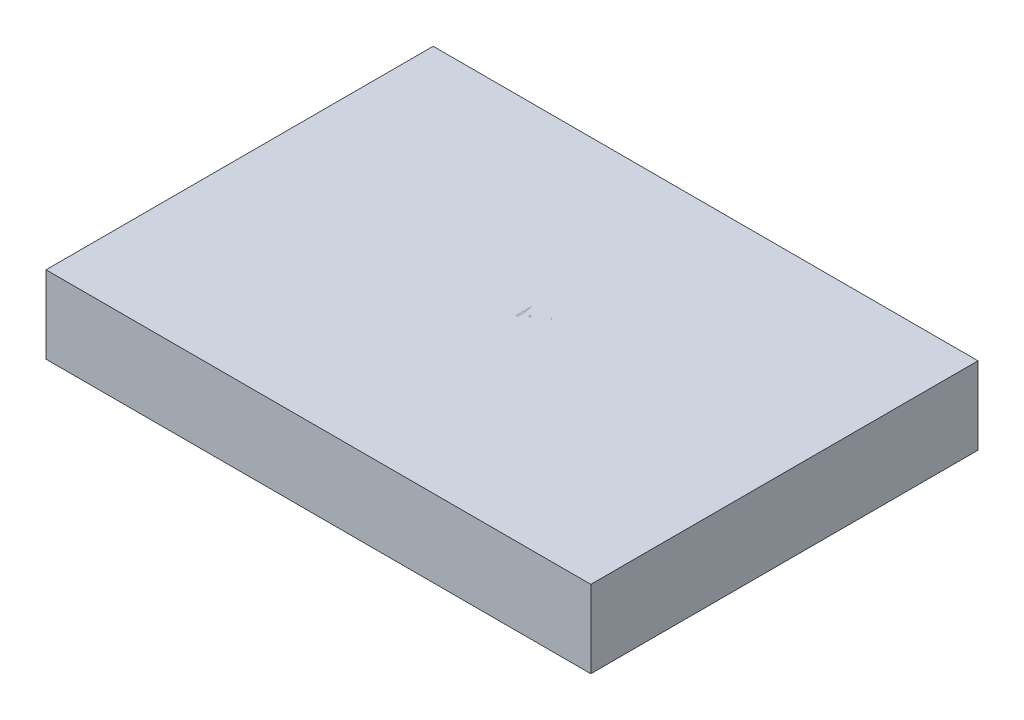
from build123d import *

# Parameters (mm, degrees)
SKETCH1_W             = 100.076
SKETCH1_H             = 71.12
BOSS_EXTRUDE1_DEPTH   = 14.224
BOSS_EXTRUDE2_DEPTH   = 0.1
BOSS_EXTRUDE2_2_DEPTH = 0.1
BOSS_EXTRUDE2_3_DEPTH = 0.1
BOSS_EXTRUDE2_4_DEPTH = 0.1
BOSS_EXTRUDE2_5_DEPTH = 0.1
BOSS_EXTRUDE2_6_DEPTH = 0.1
BOSS_EXTRUDE2_7_DEPTH = 0.1


with BuildPart() as part:
    # Sketch1 → Boss-Extrude1 (new body)
    with BuildSketch(Plane(origin=(0, 0, 0), x_dir=(1, 0, 0), z_dir=(0, 1, 0))):
        Rectangle(SKETCH1_W, SKETCH1_H)
    extrude(amount=BOSS_EXTRUDE1_DEPTH)


with BuildPart() as body_2:
    # Sketch3 → Boss-Extrude2 (new body)
    with BuildSketch(Plane(origin=(0, 14.224, 0), x_dir=(1, 0, 0), z_dir=(0, 1, 0))):
        with BuildLine():
            Line((0.407051282, 3.175), (1.026532452, 3.175))
            add(Edge.make_bspline(
                [(1.026532452, 3.175), (1.056856857, 3.174840569), (1.115633102, 3.174531553), (1.201103595, 3.169738998), (1.281157873, 3.163204241), (1.355819153, 3.152835514), (1.425052933, 3.140324401), (1.489067861, 3.125173468), (1.547660374, 3.107006469), (1.617612642, 3.078117342), (1.697369242, 3.035188468), (1.783727784, 2.97175327), (1.857573058, 2.894163107), (1.921242074, 2.806639555), (1.971861661, 2.710359248), (2.008482381, 2.607616984), (2.031667025, 2.499737975), (2.03405139, 2.425675949), (2.03525641, 2.388246194)],
                knots=[0, 0, 0, 0, 9.0959e-05, 0.000176302, 0.000256745, 0.000331852, 0.000402335, 0.000467743, 0.000529095, 0.000586142, 0.000694565, 0.000800018, 0.00090617, 0.001014562, 0.001123809, 0.001231237, 0.001341005, 0.001453163, 0.001453163, 0.001453163, 0.001453163], degree=3))
            add(Edge.make_bspline(
                [(2.03525641, 2.388246194), (2.034264705, 2.353182804), (2.032315911, 2.284279937), (2.013680693, 2.183501709), (1.984506372, 2.087570246), (1.943952325, 1.996835654), (1.891245514, 1.913348019), (1.828781182, 1.836433856), (1.753418654, 1.769349683), (1.696955144, 1.731845764), (1.668274239, 1.712795473)],
                knots=[0, 0, 0, 0, 0.000105099, 0.000206529, 0.000306317, 0.000405381, 0.000503676, 0.000601724, 0.00070171, 0.000804929, 0.000804929, 0.000804929, 0.000804929], degree=3))
            add(Edge.make_bspline(
                [(1.668274239, 1.712795473), (1.704342627, 1.698947938), (1.773350388, 1.672454174), (1.868315556, 1.625613431), (1.950135165, 1.574666374), (2.019438291, 1.519029624), (2.078708878, 1.459059489), (2.130464046, 1.393876635), (2.174625007, 1.322630762), (2.212464588, 1.246064698), (2.241990959, 1.164960259), (2.264103387, 1.080078197), (2.276773858, 0.991722887), (2.278576933, 0.931592578), (2.279487179, 0.901236979)],
                knots=[0, 0, 0, 0, 0.000115862, 0.000221672, 0.000317136, 0.000404447, 0.000487649, 0.000569596, 0.000653599, 0.000738647, 0.000825372, 0.000912066, 0.001001383, 0.001092443, 0.001092443, 0.001092443, 0.001092443], degree=3))
            add(Edge.make_bspline(
                [(2.279487179, 0.901236979), (2.278601041, 0.870242745), (2.276857537, 0.809260721), (2.263994277, 0.719675707), (2.242214587, 0.634064148), (2.212214333, 0.551872304), (2.173059948, 0.473259182), (2.12540958, 0.398135721), (2.068593805, 0.327256721), (2.005036774, 0.259834577), (1.933134684, 0.199212227), (1.855559678, 0.145222979), (1.771334802, 0.100821908), (1.681843351, 0.063523803), (1.586081435, 0.035032987), (1.48447907, 0.015100724), (1.377123882, 0.00167044), (1.303455036, 0.000566261), (1.26567508, 0)],
                knots=[0, 0, 0, 0, 9.2965e-05, 0.000182912, 0.000270839, 0.000357564, 0.000444886, 0.000533812, 0.000623905, 0.000717027, 0.000811331, 0.000905539, 0.001000006, 0.001096388, 0.001195991, 0.001299146, 0.001406751, 0.001520027, 0.001520027, 0.001520027, 0.001520027], degree=3))
            Line((1.26567508, 0), (0.407051282, 0))
            Line((0.407051282, 0), (0.407051282, 3.175))
        make_face()
        with BuildLine():
            Line((0.691987179, 2.849358974), (0.691987179, 1.831730769))
            Line((0.691987179, 1.831730769), (0.883428486, 1.831730769))
            add(Edge.make_bspline(
                [(0.883428486, 1.831730769), (0.91141275, 1.832093557), (0.965484052, 1.832794536), (1.043788529, 1.834802512), (1.116473367, 1.840425023), (1.183413101, 1.846045917), (1.244502318, 1.855185008), (1.299605678, 1.866063576), (1.349587977, 1.877568783), (1.407227422, 1.897135389), (1.472607882, 1.926052994), (1.542306484, 1.970931017), (1.603751324, 2.024383823), (1.655637345, 2.086061339), (1.698102036, 2.153975664), (1.72759662, 2.227043192), (1.747596657, 2.303442883), (1.74940326, 2.355892298), (1.750320513, 2.382522035)],
                knots=[0, 0, 0, 0, 8.3964e-05, 0.000162235, 0.00023492, 0.000302637, 0.000363711, 0.000420091, 0.000471151, 0.00051741, 0.000602525, 0.000684916, 0.00076515, 0.000845934, 0.000925893, 0.001004319, 0.001081603, 0.001161311, 0.001161311, 0.001161311, 0.001161311], degree=3))
            add(Edge.make_bspline(
                [(1.750320513, 2.382522035), (1.749843192, 2.400143985), (1.748906876, 2.434711364), (1.741238523, 2.485102564), (1.72820508, 2.532495111), (1.7114644, 2.577538482), (1.688070375, 2.618824232), (1.660526376, 2.657779845), (1.627247214, 2.693078696), (1.589367366, 2.726071026), (1.545816687, 2.755321419), (1.496621158, 2.780939826), (1.441115194, 2.801568959), (1.380234247, 2.819635755), (1.313041189, 2.832325136), (1.240311416, 2.842896423), (1.161449206, 2.848278267), (1.106889006, 2.848990704), (1.078685897, 2.849358974)],
                knots=[0, 0, 0, 0, 5.2851e-05, 0.000103672, 0.000152426, 0.000200145, 0.000247403, 0.000294352, 0.000342957, 0.000392558, 0.000444773, 0.00049996, 0.000558547, 0.000622148, 0.000690253, 0.000763469, 0.000842543, 0.000927155, 0.000927155, 0.000927155, 0.000927155], degree=3))
            Line((1.078685897, 2.849358974), (0.691987179, 2.849358974))
        make_face(mode=Mode.SUBTRACT)
        with BuildLine():
            Line((0.691987179, 1.506089744), (0.691987179, 0.325641026))
            Line((0.691987179, 0.325641026), (1.097766426, 0.325641026))
            add(Edge.make_bspline(
                [(1.097766426, 0.325641026), (1.126812166, 0.325989139), (1.182794001, 0.326660083), (1.263621545, 0.328850429), (1.338536218, 0.333832707), (1.40719617, 0.341675728), (1.470342795, 0.350183321), (1.527218568, 0.361623555), (1.578284536, 0.374730826), (1.637497658, 0.394991111), (1.704175841, 0.426465766), (1.776031403, 0.473922243), (1.839918044, 0.530458387), (1.894169958, 0.59589143), (1.93863174, 0.667039848), (1.970976332, 0.742464559), (1.99092518, 0.820919287), (1.993340148, 0.874410519), (1.994551282, 0.901236979)],
                knots=[0, 0, 0, 0, 8.7144e-05, 0.000167958, 0.000242546, 0.000312291, 0.000375253, 0.000433628, 0.000486234, 0.000533299, 0.000621212, 0.00070659, 0.000790835, 0.000876178, 0.000960721, 0.001041645, 0.001121551, 0.001201941, 0.001201941, 0.001201941, 0.001201941], degree=3))
            add(Edge.make_bspline(
                [(1.994551282, 0.901236979), (1.994300816, 0.918013081), (1.993803924, 0.951294684), (1.986310366, 1.000204035), (1.97541207, 1.047580363), (1.961322841, 1.093552313), (1.940803753, 1.137288733), (1.916849244, 1.179654626), (1.88876283, 1.220705997), (1.844998479, 1.272605684), (1.781342465, 1.332401831), (1.690894175, 1.390946565), (1.588049305, 1.438161362), (1.513457222, 1.458208744), (1.47492488, 1.468564704)],
                knots=[0, 0, 0, 0, 5.0282e-05, 9.9752e-05, 0.000148043, 0.000196116, 0.000243648, 0.000292638, 0.000342035, 0.000392605, 0.000496106, 0.000602654, 0.000714508, 0.000834032, 0.000834032, 0.000834032, 0.000834032], degree=3))
            add(Edge.make_bspline(
                [(1.47492488, 1.468564704), (1.459477057, 1.471698958), (1.425982991, 1.478494669), (1.371366115, 1.485668086), (1.309012862, 1.492058961), (1.238779252, 1.496786226), (1.160576425, 1.50167259), (1.074237363, 1.503572892), (0.980114656, 1.505840078), (0.91480729, 1.506004393), (0.880884415, 1.506089744)],
                knots=[0, 0, 0, 0, 4.7275e-05, 0.000102503, 0.000165156, 0.000235303, 0.00031366, 0.000400195, 0.000494345, 0.00059611, 0.00059611, 0.00059611, 0.00059611], degree=3))
            Line((0.880884415, 1.506089744), (0.691987179, 1.506089744))
        make_face(mode=Mode.SUBTRACT)
    extrude(amount=-BOSS_EXTRUDE2_DEPTH)


with BuildPart() as body_3:
    # Sketch3 → Boss-Extrude2 2 (new body)
    with BuildSketch(Plane(origin=(0, 14.224, 0), x_dir=(1, 0, 0), z_dir=(0, 1, 0))):
        Polygon((4.233333333, 3.175), (5.698717949, 0), (5.388977364, 0), (4.919596354, 1.017628205), (3.480288462, 1.017628205), (2.997551082, 0), (2.686538462, 0), (4.192628205, 3.175), align=None)
        Polygon((4.209800681, 2.556154848), (3.634840745, 1.343269231), (4.769496194, 1.343269231), align=None, mode=Mode.SUBTRACT)
    extrude(amount=-BOSS_EXTRUDE2_2_DEPTH)


with BuildPart() as body_4:
    # Sketch3 → Boss-Extrude2 3 (new body)
    with BuildSketch(Plane(origin=(0, 14.224, 0), x_dir=(1, 0, 0), z_dir=(0, 1, 0))):
        Polygon((5.90224359, 2.849358974), (5.90224359, 3.175), (7.571153846, 3.175), (7.571153846, 2.849358974), (6.879166667, 2.849358974), (6.879166667, 0), (6.594230769, 0), (6.594230769, 2.849358974), align=None)
    extrude(amount=-BOSS_EXTRUDE2_3_DEPTH)


with BuildPart() as body_5:
    # Sketch3 → Boss-Extrude2 4 (new body)
    with BuildSketch(Plane(origin=(0, 14.224, 0), x_dir=(1, 0, 0), z_dir=(0, 1, 0))):
        Polygon((7.693269231, 2.849358974), (7.693269231, 3.175), (9.362179487, 3.175), (9.362179487, 2.849358974), (8.670192308, 2.849358974), (8.670192308, 0), (8.38525641, 0), (8.38525641, 2.849358974), align=None)
    extrude(amount=-BOSS_EXTRUDE2_4_DEPTH)


with BuildPart() as body_6:
    # Sketch3 → Boss-Extrude2 5 (new body)
    with BuildSketch(Plane(origin=(0, 14.224, 0), x_dir=(1, 0, 0), z_dir=(0, 1, 0))):
        Polygon((9.850641026, 3.175), (11.641666667, 3.175), (11.641666667, 2.849358974), (10.135576923, 2.849358974), (10.135576923, 1.872435897), (11.641666667, 1.872435897), (11.641666667, 1.546794872), (10.135576923, 1.546794872), (10.135576923, 0.325641026), (11.641666667, 0.325641026), (11.641666667, 0), (9.850641026, 0), align=None)
    extrude(amount=-BOSS_EXTRUDE2_5_DEPTH)


with BuildPart() as body_7:
    # Sketch3 → Boss-Extrude2 6 (new body)
    with BuildSketch(Plane(origin=(0, 14.224, 0), x_dir=(1, 0, 0), z_dir=(0, 1, 0))):
        with BuildLine():
            Line((12.211538462, 3.175), (12.846920072, 3.175))
            add(Edge.make_bspline(
                [(12.846920072, 3.175), (12.889320953, 3.174858861), (12.970735341, 3.174587859), (13.087369665, 3.173076774), (13.193348532, 3.168745752), (13.288616529, 3.16501868), (13.373171908, 3.158222418), (13.447273951, 3.151726689), (13.510581362, 3.143223439), (13.548904384, 3.135326377), (13.56625601, 3.131750801)],
                knots=[0, 0, 0, 0, 0.000127205, 0.000244248, 0.000349896, 0.000445402, 0.000530231, 0.00060434, 0.000668562, 0.000721699, 0.000721699, 0.000721699, 0.000721699], degree=3))
            add(Edge.make_bspline(
                [(13.56625601, 3.131750801), (13.589484876, 3.126011521), (13.635447073, 3.114655396), (13.701623205, 3.090652758), (13.764682627, 3.062876384), (13.824363396, 3.030252152), (13.880366578, 2.992537888), (13.933269617, 2.950384662), (13.983312574, 2.904023126), (14.028471624, 2.852284377), (14.071052049, 2.798004114), (14.106964589, 2.739308563), (14.137922181, 2.677929892), (14.162569722, 2.613243877), (14.182416169, 2.545877841), (14.196409972, 2.475221576), (14.204802121, 2.401596977), (14.205656518, 2.351379445), (14.206089744, 2.325916466)],
                knots=[0, 0, 0, 0, 7.1738e-05, 0.000141945, 0.000210849, 0.000278309, 0.000345694, 0.000413139, 0.000481086, 0.000550014, 0.000618962, 0.000687796, 0.000756061, 0.000824921, 0.000895163, 0.000966511, 0.001040751, 0.001117115, 0.001117115, 0.001117115, 0.001117115], degree=3))
            add(Edge.make_bspline(
                [(14.206089744, 2.325916466), (14.204757152, 2.283611764), (14.202156922, 2.201064333), (14.177913435, 2.081266248), (14.138201878, 1.969515941), (14.083480037, 1.86595412), (14.013793798, 1.772599463), (13.930042024, 1.690602407), (13.83217799, 1.621986201), (13.741074254, 1.574404013), (13.660597801, 1.543930446), (13.594346153, 1.522488892), (13.522076824, 1.505922681), (13.444482241, 1.491081704), (13.361239497, 1.479876953), (13.272548104, 1.471670399), (13.178344809, 1.466541369), (13.113630082, 1.465777551), (13.080338542, 1.465384615)],
                knots=[0, 0, 0, 0, 0.000126797, 0.000247415, 0.000364897, 0.000481551, 0.000597433, 0.000713022, 0.000831615, 0.000954788, 0.001020224, 0.001089619, 0.001163513, 0.001242474, 0.001326575, 0.001415367, 0.001509635, 0.001609508, 0.001609508, 0.001609508, 0.001609508], degree=3))
            Line((13.080338542, 1.465384615), (14.246794872, 0))
            Line((14.246794872, 0), (13.894441106, 0))
            Line((13.894441106, 0), (12.727984776, 1.465384615))
            Line((12.727984776, 1.465384615), (12.496474359, 1.465384615))
            Line((12.496474359, 1.465384615), (12.496474359, 0))
            Line((12.496474359, 0), (12.211538462, 0))
            Line((12.211538462, 0), (12.211538462, 3.175))
        make_face()
        with BuildLine():
            Line((12.496474359, 2.849358974), (12.496474359, 1.791025641))
            Line((12.496474359, 1.791025641), (13.077794471, 1.786573518))
            add(Edge.make_bspline(
                [(13.077794471, 1.786573518), (13.104936221, 1.78656151), (13.157544662, 1.786538236), (13.233654551, 1.790161162), (13.304520652, 1.7942826), (13.369871906, 1.80058665), (13.429737506, 1.808711086), (13.484087531, 1.818873793), (13.5330107, 1.830713879), (13.590068659, 1.849039639), (13.653783227, 1.87807367), (13.723026766, 1.920315229), (13.781993172, 1.973445788), (13.831811519, 2.03420028), (13.871843217, 2.100998877), (13.900066295, 2.173040869), (13.917975511, 2.248507533), (13.920087834, 2.300376245), (13.921153846, 2.326552484)],
                knots=[0, 0, 0, 0, 8.1413e-05, 0.000157801, 0.000228539, 0.000294357, 0.000354712, 0.000409723, 0.000460165, 0.000505621, 0.000589315, 0.00066961, 0.000747992, 0.000826171, 0.000904597, 0.000980539, 0.001057529, 0.001135968, 0.001135968, 0.001135968, 0.001135968], degree=3))
            add(Edge.make_bspline(
                [(13.921153846, 2.326552484), (13.920063351, 2.352085447), (13.917902386, 2.402682464), (13.900259575, 2.47675604), (13.870424207, 2.546666773), (13.830217606, 2.61213027), (13.781232658, 2.67155333), (13.723794357, 2.722396105), (13.659473215, 2.764350976), (13.599355771, 2.791161022), (13.545621878, 2.807598317), (13.49896783, 2.819165444), (13.446252418, 2.828458641), (13.38721968, 2.835904525), (13.322121629, 2.842304367), (13.25062911, 2.846614909), (13.17321646, 2.849167486), (13.119561743, 2.849293659), (13.091786859, 2.849358974)],
                knots=[0, 0, 0, 0, 7.6536e-05, 0.000151667, 0.000226914, 0.000303706, 0.000381394, 0.000457083, 0.00053294, 0.00061095, 0.000653596, 0.000701416, 0.000755061, 0.00081407, 0.000879888, 0.000951261, 0.001028897, 0.001112218, 0.001112218, 0.001112218, 0.001112218], degree=3))
            Line((13.091786859, 2.849358974), (12.496474359, 2.849358974))
        make_face(mode=Mode.SUBTRACT)
    extrude(amount=-BOSS_EXTRUDE2_6_DEPTH)


with BuildPart() as body_8:
    # Sketch3 → Boss-Extrude2 7 (new body)
    with BuildSketch(Plane(origin=(0, 14.224, 0), x_dir=(1, 0, 0), z_dir=(0, 1, 0))):
        Polygon((14.653846154, 3.175), (14.980123197, 3.175), (15.814578325, 1.810742188), (16.647761418, 3.175), (16.974038462, 3.175), (15.956410256, 1.509269832), (15.956410256, 0), (15.671474359, 0), (15.671474359, 1.509269832), align=None)
    extrude(amount=-BOSS_EXTRUDE2_7_DEPTH)


solid = Compound([part.part, body_2.part, body_3.part, body_4.part, body_5.part, body_6.part, body_7.part, body_8.part])
